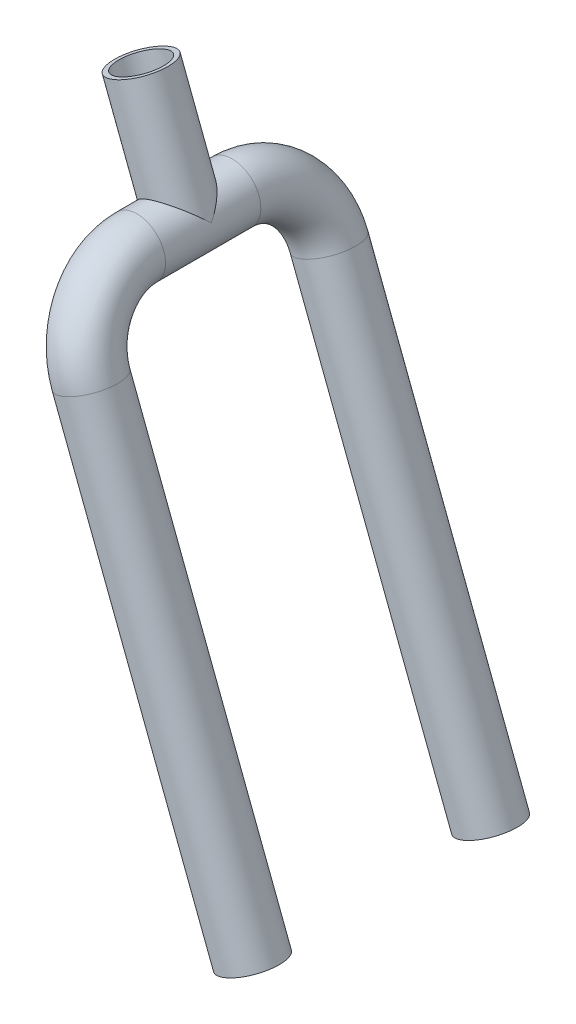
from build123d import *

# Parameters (mm, degrees)
SWEEP_THIN1_PROFILE_R   = 12
SWEEP_THIN1_PROFILE_R_2 = 10


with BuildPart() as part:
    # Sweep-Thin1: sweep along a path in Sketch2
    with BuildLine(Plane(origin=(400, -300, 0), x_dir=(0, 0, -1), z_dir=(0.934155191329314, 0.35686703197758807, 0))) as sweep_thin1_path:
        Line((0, 251.145783), (0, 200))
        Line((0, 200), (-20, 200))
        ThreePointArc((-20, 200), (-41.213203, 191.213203), (-50, 170))
        Line((-50, 170), (-50, -20))
    # Sweep-Thin1 profile (on start of the path) → Sweep-Thin1 (sweep)
    with BuildSketch(Plane(origin=(310.37435, -65.390863, 0), x_dir=(-0.934155191329314, -0.35686703197758807, 0), z_dir=(0.35686703197758807, -0.934155191329314, 0))):
        Circle(SWEEP_THIN1_PROFILE_R)
        Circle(SWEEP_THIN1_PROFILE_R_2, mode=Mode.SUBTRACT)
    sweep_thin1 = sweep(path=sweep_thin1_path.line, transition=Transition.RIGHT)

    # Mirror1: Sweep-Thin1 across plane
    add(sweep_thin1.mirror(Plane.XY))


solid = part.part
